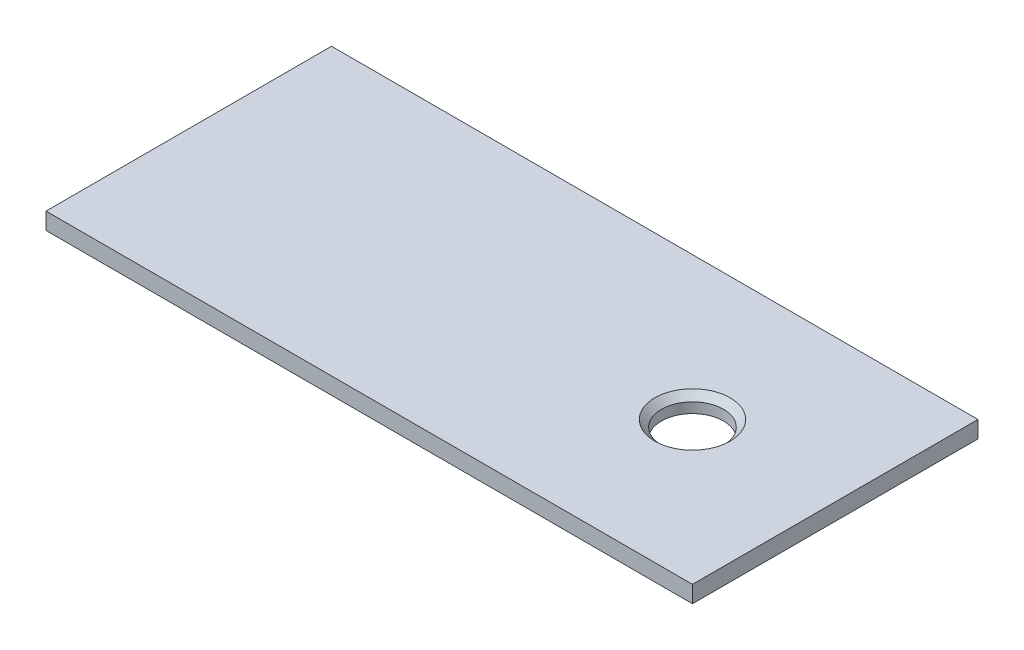
from build123d import *

# Parameters (mm, degrees)
SKETCH1_W                         = 120
SKETCH1_H                         = 53
BOSS_EXTRUDE1_DEPTH               = 3.125
F_1_2_20_TAPPED_HOLE1_D           = 11.50874
F_1_2_20_TAPPED_HOLE1_DEPTH       = 30
F_1_2_20_TAPPED_HOLE1_CSINK_D     = 13.97
F_1_2_20_TAPPED_HOLE1_CSINK_ANGLE = 90
F_1_2_20_TAPPED_HOLE1_TIP         = 3.45757432


with BuildPart() as part:
    # Sketch1 → Boss-Extrude1 (new body)
    with BuildSketch(Plane(origin=(0, 0, 0), x_dir=(1, 0, 0), z_dir=(0, 1, 0))):
        Rectangle(SKETCH1_W, SKETCH1_H)
    extrude(amount=BOSS_EXTRUDE1_DEPTH)

    # 1/2-20 Tapped Hole1
    with Locations(Plane(origin=(0, 3.125, 0), x_dir=(1, 0, 0), z_dir=(0, 1, 0))):
        with Locations((33.5, 0)):
            CounterSinkHole(F_1_2_20_TAPPED_HOLE1_D / 2, F_1_2_20_TAPPED_HOLE1_CSINK_D / 2, depth=F_1_2_20_TAPPED_HOLE1_DEPTH, counter_sink_angle=F_1_2_20_TAPPED_HOLE1_CSINK_ANGLE)
            with Locations((0, 0, -(F_1_2_20_TAPPED_HOLE1_DEPTH + F_1_2_20_TAPPED_HOLE1_TIP / 2))):  # 118° drill point
                Cone(0, F_1_2_20_TAPPED_HOLE1_D / 2, F_1_2_20_TAPPED_HOLE1_TIP, mode=Mode.SUBTRACT)


solid = part.part
